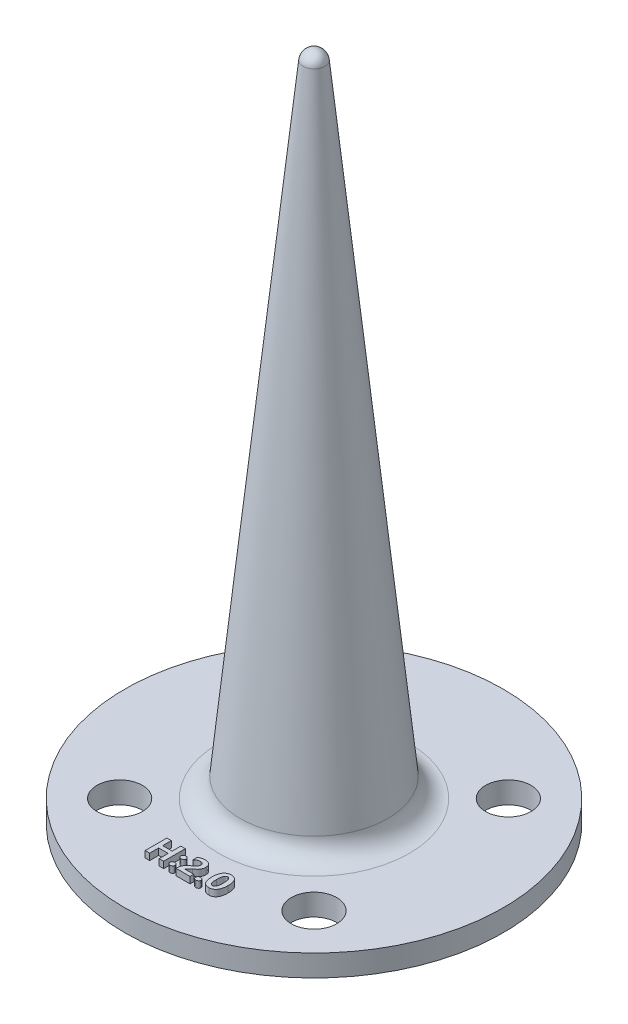
from build123d import *

# Parameters (mm, degrees)
SKETCH_1_R          = 17.5
EXTRUDE_1_DEPTH     = 2
SKETCH_2_R          = 2.1
CUT_EXTRUDE_1_DEPTH = 3
EXTRUDE_2_DEPTH     = 0.6


with BuildPart() as part:
    # 草图1 → 凸台-拉伸1 (new body)
    with BuildSketch(Plane(origin=(0, 0, 0), x_dir=(1, 0, 0), z_dir=(0, 1, 0))):
        Circle(SKETCH_1_R)
    extrude(amount=EXTRUDE_1_DEPTH)

    # 草图2 → 切除-拉伸1 (cut, through all)
    with BuildSketch(Plane(origin=(0, 2, 0), x_dir=(1, 0, 0), z_dir=(0, 1, 0))):
        with Locations((-8.980256121, 8.980256121)):
            Circle(SKETCH_2_R)
        with Locations((8.980256121, 8.980256121)):
            Circle(SKETCH_2_R)
        with Locations((8.980256121, -8.980256121)):
            Circle(SKETCH_2_R)
        with Locations((-8.980256121, -8.980256121)):
            Circle(SKETCH_2_R)
    extrude(amount=-CUT_EXTRUDE_1_DEPTH, mode=Mode.SUBTRACT)

    # 草图3 → 旋转1 (revolve)
    with BuildSketch(Plane.XY):
        with BuildLine():
            Line((0, 2), (0, 62))
            ThreePointArc((0, 62), (0.673890627, 61.740633618), (1, 61.096388188))
            Line((1, 61.096388188), (6.817452757, 3.797980459))
            ThreePointArc((6.817452757, 3.797980459), (7.466335687, 2.516079672), (8.807223624, 2))
            Line((8.807223624, 2), (8.5, 2))
            Line((8.5, 2), (8.5, 0))
            Line((8.5, 0), (3.5, 0))
            Line((3.5, 0), (3, 0))
            Line((3, 0), (3, -0.5))
            Line((3, -0.5), (3, -1.5))
            ThreePointArc((3, -1.5), (2.853553391, -1.853553391), (2.5, -2))
            Line((2.5, -2), (0, -2))
            Line((0, -2), (0, 2))
        make_face()
    revolve(axis=Axis((0, 2, 0), (0, 1, 0)))

    # 草图4 → 凸台-拉伸2 (add)
    with BuildSketch(Plane(origin=(0, 2, 0), x_dir=(1, 0, 0), z_dir=(0, 1, 0))):
        Polygon((-1.323843075, -12.567331469), (-1.738477221, -12.567331469), (-1.738477221, -11.738063176), (-2.616526001, -11.738063176), (-2.616526001, -12.567331469), (-3.031160148, -12.567331469), (-3.031160148, -10.567331469), (-2.616526001, -10.567331469), (-2.616526001, -11.372209517), (-1.738477221, -11.372209517), (-1.738477221, -10.567331469), (-1.323843075, -10.567331469), align=None)
        with BuildLine():
            add(Edge.make_bspline(
                [(-0.957989416, -11.346675981), (-0.95716336, -11.331445974), (-0.955544486, -11.301598759), (-0.941197888, -11.259229371), (-0.918119217, -11.221146155), (-0.88613114, -11.188748831), (-0.848424144, -11.161948655), (-0.806167375, -11.142050636), (-0.76018352, -11.130416952), (-0.728380096, -11.129019069), (-0.712181489, -11.128307078)],
                knots=[0, 0, 0, 0, 4.5581e-05, 8.9327e-05, 0.000132595, 0.000178144, 0.000224882, 0.000270744, 0.000317513, 0.000366062, 0.000366062, 0.000366062, 0.000366062], degree=3))
            add(Edge.make_bspline(
                [(-0.712181489, -11.128307078), (-0.695851189, -11.12899747), (-0.664034664, -11.13034257), (-0.618206773, -11.142087334), (-0.576404646, -11.161745304), (-0.539702879, -11.18892213), (-0.508433005, -11.22116108), (-0.486265945, -11.259379701), (-0.472227311, -11.301630702), (-0.470875143, -11.331447409), (-0.470184538, -11.346675981)],
                knots=[0, 0, 0, 0, 4.8929e-05, 9.5329e-05, 0.000140846, 0.000186657, 0.00023168, 0.000274556, 0.000318185, 0.000363729, 0.000363729, 0.000363729, 0.000363729], degree=3))
            add(Edge.make_bspline(
                [(-0.470184538, -11.346675981), (-0.470849899, -11.362415764), (-0.472142348, -11.392989926), (-0.486282231, -11.436206274), (-0.508206147, -11.475112275), (-0.539662097, -11.507587912), (-0.576920566, -11.534398068), (-0.619684238, -11.553615456), (-0.666968723, -11.565357894), (-0.700042897, -11.566659034), (-0.717135758, -11.567331469)],
                knots=[0, 0, 0, 0, 4.7062e-05, 9.1417e-05, 0.000134952, 0.000179975, 0.000225872, 0.00027192, 0.000319799, 0.000371008, 0.000371008, 0.000371008, 0.000371008], degree=3))
            add(Edge.make_bspline(
                [(-0.717135758, -11.567331469), (-0.733605837, -11.56670081), (-0.765483119, -11.565480191), (-0.81124129, -11.553045824), (-0.852871025, -11.533211309), (-0.889397668, -11.505530627), (-0.920092508, -11.472566482), (-0.941773297, -11.43396112), (-0.955978362, -11.391735934), (-0.957309534, -11.361909514), (-0.957989416, -11.346675981)],
                knots=[0, 0, 0, 0, 4.9309e-05, 9.5436e-05, 0.000141117, 0.000186849, 0.000232172, 0.000275187, 0.000318816, 0.00036436, 0.00036436, 0.00036436, 0.00036436], degree=3))
        make_face()
        with BuildLine():
            add(Edge.make_bspline(
                [(-0.957989416, -12.371447322), (-0.95718102, -12.356085454), (-0.955603155, -12.326101464), (-0.941098665, -12.283549923), (-0.918237461, -12.245222672), (-0.886233407, -12.212725737), (-0.848299387, -12.186393303), (-0.806183118, -12.166417675), (-0.760179376, -12.154813304), (-0.728378697, -12.153411375), (-0.712181489, -12.152697322)],
                knots=[0, 0, 0, 0, 4.596e-05, 8.9706e-05, 0.0001333, 0.000178849, 0.000225368, 0.000271229, 0.000317999, 0.000366548, 0.000366548, 0.000366548, 0.000366548], degree=3))
            add(Edge.make_bspline(
                [(-0.712181489, -12.152697322), (-0.69584372, -12.153353103), (-0.663980798, -12.154632047), (-0.618174177, -12.1668924), (-0.576381144, -12.186911133), (-0.539671288, -12.214464672), (-0.508527719, -12.24703996), (-0.48634338, -12.285186275), (-0.472257807, -12.327030226), (-0.470883531, -12.356472302), (-0.470184538, -12.371447322)],
                knots=[0, 0, 0, 0, 4.8929e-05, 9.5425e-05, 0.000141105, 0.000187143, 0.000232444, 0.00027532, 0.000318586, 0.000363371, 0.000363371, 0.000363371, 0.000363371], degree=3))
            add(Edge.make_bspline(
                [(-0.470184538, -12.371447322), (-0.470849811, -12.3871873), (-0.47214209, -12.41776184), (-0.486283189, -12.460975495), (-0.508202569, -12.499891532), (-0.539676089, -12.532328299), (-0.576824735, -12.55925669), (-0.619788185, -12.577900881), (-0.666954143, -12.589780455), (-0.70003793, -12.591060289), (-0.717135758, -12.591721712)],
                knots=[0, 0, 0, 0, 4.7062e-05, 9.1417e-05, 0.000134952, 0.000179975, 0.000225872, 0.000271763, 0.000319642, 0.000370851, 0.000370851, 0.000370851, 0.000370851], degree=3))
            add(Edge.make_bspline(
                [(-0.717135758, -12.591721712), (-0.733224602, -12.591077211), (-0.764597137, -12.589820463), (-0.80965975, -12.577387318), (-0.851220081, -12.557735722), (-0.888258352, -12.530469062), (-0.919151982, -12.49720983), (-0.942051611, -12.459037965), (-0.955335427, -12.41638076), (-0.957091175, -12.386655017), (-0.957989416, -12.371447322)],
                knots=[0, 0, 0, 0, 4.8169e-05, 9.3928e-05, 0.0001391, 0.000185444, 0.000231025, 0.000274423, 0.000317937, 0.000363517, 0.000363517, 0.000363517, 0.000363517], degree=3))
        make_face()
        with BuildLine():
            Line((0.302300218, -12.225868054), (1.115181316, -12.225868054))
            Line((1.115181316, -12.225868054), (1.115181316, -12.567331469))
            Line((1.115181316, -12.567331469), (-0.177501611, -12.567331469))
            Line((-0.177501611, -12.567331469), (-0.177501611, -12.419465615))
            add(Edge.make_bspline(
                [(-0.177501611, -12.419465615), (-0.17695135, -12.394012033), (-0.175872822, -12.344122234), (-0.164168835, -12.27113647), (-0.146579914, -12.20139775), (-0.121029132, -12.134990743), (-0.088953921, -12.071796884), (-0.052440887, -12.010355596), (-0.009719241, -11.95164494), (0.030043961, -11.904088875), (0.065689748, -11.866292956), (0.096513551, -11.836998947), (0.130314519, -11.806104684), (0.167751704, -11.774166102), (0.208572584, -11.740877334), (0.253158178, -11.706883939), (0.300845552, -11.671148845), (0.33424847, -11.647654921), (0.351461803, -11.635547932)],
                knots=[0, 0, 0, 0, 7.6297e-05, 0.000149544, 0.000221179, 0.000291744, 0.000362473, 0.000433582, 0.000505928, 0.000580047, 0.000619405, 0.000661721, 0.000707583, 0.000756772, 0.000809328, 0.000865582, 0.000924957, 0.000988087, 0.000988087, 0.000988087, 0.000988087], degree=3))
            add(Edge.make_bspline(
                [(0.351461803, -11.635547932), (0.367039597, -11.623963625), (0.39734499, -11.601427252), (0.440090709, -11.566964562), (0.480196071, -11.534481677), (0.515635387, -11.501988036), (0.54804717, -11.471226459), (0.576189786, -11.440999242), (0.601057762, -11.412066044), (0.62932072, -11.375597304), (0.657686293, -11.329104045), (0.682441537, -11.271158414), (0.697638273, -11.211141714), (0.699575647, -11.170440049), (0.700547169, -11.150029639)],
                knots=[0, 0, 0, 0, 5.8232e-05, 0.000113286, 0.000164715, 0.000213013, 0.000257484, 0.000298736, 0.000336847, 0.00037191, 0.000437074, 0.000499575, 0.000560394, 0.000621571, 0.000621571, 0.000621571, 0.000621571], degree=3))
            add(Edge.make_bspline(
                [(0.700547169, -11.150029639), (0.70034174, -11.139348855), (0.699941985, -11.118564513), (0.696440825, -11.088352586), (0.690864686, -11.060126142), (0.682789067, -11.033957923), (0.672602834, -11.009848657), (0.659929422, -10.988050016), (0.645179625, -10.968156612), (0.628090735, -10.950284972), (0.608488082, -10.934524777), (0.586477841, -10.921199027), (0.562506026, -10.909745713), (0.536154912, -10.900564467), (0.507567265, -10.893448971), (0.476757403, -10.888089926), (0.443618951, -10.885103855), (0.420827402, -10.884643423), (0.409007535, -10.884404639)],
                knots=[0, 0, 0, 0, 3.2033e-05, 6.2334e-05, 9.1109e-05, 0.000118231, 0.000144352, 0.000169453, 0.000193691, 0.000218488, 0.000243426, 0.000268917, 0.000295509, 0.000322991, 0.000352476, 0.000383802, 0.000416718, 0.000452179, 0.000452179, 0.000452179, 0.000452179], degree=3))
            add(Edge.make_bspline(
                [(0.409007535, -10.884404639), (0.387751303, -10.884920316), (0.34525862, -10.885951188), (0.282119243, -10.896525092), (0.219557516, -10.912481759), (0.157749125, -10.935035608), (0.096769454, -10.96438342), (0.036677531, -10.999917596), (-0.023002881, -11.041655558), (-0.060635022, -11.073738498), (-0.079940636, -11.090197322)],
                knots=[0, 0, 0, 0, 6.3716e-05, 0.000127373, 0.000191521, 0.000257226, 0.000324387, 0.000394257, 0.00046647, 0.000542542, 0.000542542, 0.000542542, 0.000542542], degree=3))
            Line((-0.079940636, -11.090197322), (-0.079940636, -10.71557842))
            add(Edge.make_bspline(
                [(-0.079940636, -10.71557842), (-0.058675113, -10.701774347), (-0.016428373, -10.674350753), (0.050219626, -10.639400852), (0.118594547, -10.609556019), (0.188858318, -10.584953652), (0.261229687, -10.566502652), (0.335391836, -10.552524654), (0.411623688, -10.544492216), (0.463105327, -10.543460785), (0.489038023, -10.542941225)],
                knots=[0, 0, 0, 0, 7.6026e-05, 0.000151035, 0.000225447, 0.00029969, 0.000374098, 0.000449293, 0.000525932, 0.000603722, 0.000603722, 0.000603722, 0.000603722], degree=3))
            add(Edge.make_bspline(
                [(0.489038023, -10.542941225), (0.512560682, -10.543317501), (0.558453503, -10.544051619), (0.625319805, -10.551582694), (0.688507189, -10.56308906), (0.747766624, -10.580004885), (0.803449276, -10.601190904), (0.855107992, -10.627834459), (0.903494167, -10.658485001), (0.947130596, -10.694667048), (0.987095939, -10.733941391), (1.021191598, -10.777976033), (1.050198682, -10.825445888), (1.074459103, -10.876287804), (1.092770001, -10.930967855), (1.105458259, -10.989122936), (1.113791928, -11.050832054), (1.114710129, -11.093217865), (1.115181316, -11.114968664)],
                knots=[0, 0, 0, 0, 7.054e-05, 0.000137624, 0.000201605, 0.000263009, 0.000322246, 0.000380025, 0.00043711, 0.000493714, 0.000549765, 0.000604882, 0.000660308, 0.000716393, 0.000773517, 0.000832875, 0.000894751, 0.000959974, 0.000959974, 0.000959974, 0.000959974], degree=3))
            add(Edge.make_bspline(
                [(1.115181316, -11.114968664), (1.114639664, -11.139265359), (1.113580681, -11.18676785), (1.104011334, -11.256120684), (1.089523556, -11.322142365), (1.067852781, -11.384591499), (1.040441697, -11.444120388), (1.007792065, -11.501522054), (0.970030467, -11.557374408), (0.933628125, -11.602195705), (0.900879082, -11.638063948), (0.872456133, -11.666211926), (0.840931075, -11.695953467), (0.80567076, -11.726751696), (0.767287418, -11.759164957), (0.725155052, -11.792747578), (0.679626012, -11.827629946), (0.647866934, -11.851046201), (0.631568511, -11.863063176)],
                knots=[0, 0, 0, 0, 7.2853e-05, 0.000142436, 0.000209649, 0.000275331, 0.000340304, 0.000406008, 0.000473234, 0.000542335, 0.000579019, 0.000618902, 0.000662308, 0.000709022, 0.00075933, 0.000813015, 0.00087064, 0.000931387, 0.000931387, 0.000931387, 0.000931387], degree=3))
            add(Edge.make_bspline(
                [(0.631568511, -11.863063176), (0.615912954, -11.874836855), (0.585858831, -11.897438901), (0.543004671, -11.930676787), (0.504283904, -11.961838331), (0.469254371, -11.990814628), (0.438735897, -12.018148974), (0.411758955, -12.04300171), (0.388783958, -12.06569163), (0.364692866, -12.092822217), (0.340695838, -12.123952009), (0.318986867, -12.159710362), (0.305269496, -12.193403371), (0.303238719, -12.215606922), (0.302300218, -12.225868054)],
                knots=[0, 0, 0, 0, 5.8766e-05, 0.000112813, 0.000162689, 0.000207873, 0.000249174, 0.000285578, 0.000317915, 0.000345987, 0.000394388, 0.000435565, 0.000471382, 0.000502156, 0.000502156, 0.000502156, 0.000502156], degree=3))
        make_face()
        with BuildLine():
            add(Edge.make_bspline(
                [(1.432254486, -12.371447322), (1.433062883, -12.356085454), (1.434640747, -12.326101464), (1.449145237, -12.283549923), (1.472006441, -12.245222672), (1.504010496, -12.212725737), (1.541944516, -12.186393303), (1.584060784, -12.166417675), (1.630064527, -12.154813304), (1.661865205, -12.153411375), (1.678062413, -12.152697322)],
                knots=[0, 0, 0, 0, 4.596e-05, 8.9706e-05, 0.0001333, 0.000178849, 0.000225368, 0.000271229, 0.000317999, 0.000366548, 0.000366548, 0.000366548, 0.000366548], degree=3))
            add(Edge.make_bspline(
                [(1.678062413, -12.152697322), (1.694400183, -12.153353103), (1.726263105, -12.154632047), (1.772069725, -12.1668924), (1.813862758, -12.186911133), (1.850572614, -12.214464672), (1.881716184, -12.24703996), (1.903900523, -12.285186275), (1.917986095, -12.327030226), (1.919360371, -12.356472302), (1.920059364, -12.371447322)],
                knots=[0, 0, 0, 0, 4.8929e-05, 9.5425e-05, 0.000141105, 0.000187143, 0.000232444, 0.00027532, 0.000318586, 0.000363371, 0.000363371, 0.000363371, 0.000363371], degree=3))
            add(Edge.make_bspline(
                [(1.920059364, -12.371447322), (1.919394091, -12.3871873), (1.918101813, -12.41776184), (1.903960713, -12.460975495), (1.882041333, -12.499891532), (1.850567813, -12.532328299), (1.813419168, -12.55925669), (1.770455718, -12.577900881), (1.72328976, -12.589780455), (1.690205973, -12.591060289), (1.673108145, -12.591721712)],
                knots=[0, 0, 0, 0, 4.7062e-05, 9.1417e-05, 0.000134952, 0.000179975, 0.000225872, 0.000271763, 0.000319642, 0.000370851, 0.000370851, 0.000370851, 0.000370851], degree=3))
            add(Edge.make_bspline(
                [(1.673108145, -12.591721712), (1.657019301, -12.591077211), (1.625646765, -12.589820463), (1.580584152, -12.577387318), (1.539023821, -12.557735722), (1.50198555, -12.530469062), (1.47109192, -12.49720983), (1.448192291, -12.459037965), (1.434908475, -12.41638076), (1.433152727, -12.386655017), (1.432254486, -12.371447322)],
                knots=[0, 0, 0, 0, 4.8169e-05, 9.3928e-05, 0.0001391, 0.000185444, 0.000231025, 0.000274423, 0.000317937, 0.000363517, 0.000363517, 0.000363517, 0.000363517], degree=3))
        make_face()
        with BuildLine():
            add(Edge.make_bspline(
                [(2.163961803, -11.599343664), (2.164564428, -11.557790574), (2.165736072, -11.47700156), (2.174269597, -11.359623021), (2.189591363, -11.249814531), (2.210291711, -11.147643327), (2.236766009, -11.052786324), (2.269874155, -10.965814616), (2.308840212, -10.88619311), (2.353755047, -10.814263336), (2.404564667, -10.750256357), (2.460788125, -10.694440754), (2.522761513, -10.647535845), (2.590008535, -10.609113232), (2.662659213, -10.57926711), (2.740568731, -10.557924555), (2.823858042, -10.545206624), (2.881142169, -10.543709386), (2.910531925, -10.542941225)],
                knots=[0, 0, 0, 0, 0.000124656, 0.000242361, 0.000352793, 0.000457056, 0.000554894, 0.000647895, 0.00073584, 0.00082043, 0.00090179, 0.000980479, 0.001057462, 0.001134275, 0.001212195, 0.001292447, 0.001376096, 0.001464229, 0.001464229, 0.001464229, 0.001464229], degree=3))
            add(Edge.make_bspline(
                [(2.910531925, -10.542941225), (2.93852253, -10.543603125), (2.992990287, -10.544891136), (3.071895914, -10.556878365), (3.145489596, -10.576680766), (3.213639305, -10.604542959), (3.276537768, -10.640257988), (3.333648174, -10.684175625), (3.38570391, -10.735750408), (3.431774241, -10.795622542), (3.472375647, -10.863351353), (3.507126605, -10.938913966), (3.53756529, -11.021857284), (3.560991264, -11.11313424), (3.580080779, -11.212005478), (3.593582161, -11.318798905), (3.601562154, -11.433442852), (3.602501273, -11.512440072), (3.602986194, -11.553230859)],
                knots=[0, 0, 0, 0, 8.3928e-05, 0.000163318, 0.000238757, 0.000312076, 0.000383594, 0.000455091, 0.000527581, 0.00060282, 0.000681118, 0.000763978, 0.000851986, 0.000945811, 0.001046338, 0.001153923, 0.001268532, 0.001390894, 0.001390894, 0.001390894, 0.001390894], degree=3))
            add(Edge.make_bspline(
                [(3.602986194, -11.553230859), (3.602412661, -11.593517629), (3.601298541, -11.671777047), (3.592362315, -11.785647432), (3.578255989, -11.89250351), (3.557752222, -11.992396127), (3.531176465, -12.085179992), (3.498863148, -12.170939615), (3.460700711, -12.249679572), (3.41661925, -12.321030059), (3.366894951, -12.384808628), (3.31191854, -12.440402016), (3.251542833, -12.487679492), (3.185309296, -12.52535312), (3.11436143, -12.555362827), (3.038096284, -12.576789786), (2.95656095, -12.589431253), (2.900414678, -12.590945968), (2.871659974, -12.591721712)],
                knots=[0, 0, 0, 0, 0.000120846, 0.000234751, 0.000342437, 0.00044401, 0.000540382, 0.000631688, 0.000718612, 0.000802475, 0.000882828, 0.000960707, 0.001036481, 0.001112112, 0.001188625, 0.001267042, 0.001349185, 0.001435415, 0.001435415, 0.001435415, 0.001435415], degree=3))
            add(Edge.make_bspline(
                [(2.871659974, -12.591721712), (2.843031787, -12.591077096), (2.787421034, -12.589824917), (2.706826583, -12.577631073), (2.631700484, -12.558460658), (2.562058224, -12.531206013), (2.497767654, -12.496335083), (2.439103669, -12.453473241), (2.386380025, -12.402298546), (2.338976762, -12.343745654), (2.297335049, -12.277264469), (2.261528791, -12.203046256), (2.231100402, -12.121255088), (2.206627308, -12.031658835), (2.187139289, -11.934518247), (2.173888157, -11.829568513), (2.165247593, -11.716994071), (2.164399314, -11.639376103), (2.163961803, -11.599343664)],
                knots=[0, 0, 0, 0, 8.5832e-05, 0.000166729, 0.000243912, 0.000318008, 0.000390486, 0.000462747, 0.000535249, 0.000610302, 0.000688227, 0.000770039, 0.000857106, 0.000949659, 0.00104839, 0.001154086, 0.001266822, 0.001386897, 0.001386897, 0.001386897, 0.001386897], degree=3))
        make_face()
        with BuildLine():
            add(Edge.make_bspline(
                [(2.57859595, -11.58905403), (2.578751886, -11.616753184), (2.579053907, -11.670401316), (2.583163143, -11.748038178), (2.58855616, -11.820409393), (2.596803882, -11.887463698), (2.607924227, -11.949098985), (2.620695165, -12.005567388), (2.636006363, -12.056669525), (2.654617098, -12.102210986), (2.674339079, -12.142967068), (2.697416385, -12.177948343), (2.722764946, -12.2077962), (2.750571619, -12.23247953), (2.781165857, -12.251453322), (2.813993536, -12.264917061), (2.849272375, -12.273237202), (2.873645959, -12.274170211), (2.886141681, -12.274648542)],
                knots=[0, 0, 0, 0, 8.3087e-05, 0.000160924, 0.000233178, 0.000300773, 0.000363493, 0.000420993, 0.000474397, 0.000523298, 0.000568462, 0.000610002, 0.000648651, 0.000685649, 0.000721077, 0.000756109, 0.0007917, 0.000829143, 0.000829143, 0.000829143, 0.000829143], degree=3))
            add(Edge.make_bspline(
                [(2.886141681, -12.274648542), (2.898388997, -12.274193007), (2.922424935, -12.273299), (2.957080338, -12.264565602), (2.989441464, -12.250618226), (3.019300194, -12.230970902), (3.046735258, -12.205685209), (3.071463222, -12.174825551), (3.093920092, -12.138681491), (3.114205814, -12.097235792), (3.131545847, -12.050028052), (3.146475165, -11.99733178), (3.160100441, -11.939439242), (3.169874533, -11.875803248), (3.17837029, -11.806810974), (3.184384239, -11.732183337), (3.187723288, -11.652093681), (3.188138058, -11.596933255), (3.188352047, -11.568474761)],
                knots=[0, 0, 0, 0, 3.6682e-05, 7.1991e-05, 0.000106469, 0.000141985, 0.00017867, 0.000217952, 0.000260247, 0.000306095, 0.000356141, 0.000410897, 0.000470339, 0.000534433, 0.000603919, 0.000678863, 0.000758967, 0.00084434, 0.00084434, 0.00084434, 0.00084434], degree=3))
            add(Edge.make_bspline(
                [(3.188352047, -11.568474761), (3.188146901, -11.53988873), (3.187749214, -11.484473363), (3.184294758, -11.404146533), (3.178721894, -11.329390641), (3.170732148, -11.260227419), (3.160728338, -11.196424434), (3.147673953, -11.138223183), (3.13309668, -11.085395179), (3.115922784, -11.038227027), (3.096639345, -10.996319738), (3.07471881, -10.960050861), (3.050309401, -10.929386818), (3.024047605, -10.903694589), (2.994782804, -10.884084765), (2.963204732, -10.870094479), (2.929417322, -10.861396573), (2.906010608, -10.860479367), (2.89414473, -10.860014395)],
                knots=[0, 0, 0, 0, 8.5755e-05, 0.000166239, 0.000241153, 0.000310594, 0.000375064, 0.000434794, 0.000489445, 0.000539359, 0.000585221, 0.000627639, 0.000666147, 0.000702535, 0.000737416, 0.000771196, 0.000805765, 0.000841307, 0.000841307, 0.000841307, 0.000841307], degree=3))
            add(Edge.make_bspline(
                [(2.89414473, -10.860014395), (2.881382268, -10.860432965), (2.856299346, -10.861255607), (2.820195488, -10.870544149), (2.786241083, -10.884620246), (2.75527104, -10.905368193), (2.726335113, -10.931102203), (2.700333537, -10.962834764), (2.677130016, -11.000256895), (2.656253007, -11.043219791), (2.63761987, -11.091781983), (2.62174436, -11.146103184), (2.608610929, -11.206121332), (2.597673779, -11.271762247), (2.58888011, -11.343082239), (2.583092091, -11.420024769), (2.579069708, -11.502629107), (2.578757534, -11.559577125), (2.57859595, -11.58905403)],
                knots=[0, 0, 0, 0, 3.8203e-05, 7.5083e-05, 0.000111112, 0.000148002, 0.000186328, 0.000226926, 0.000270594, 0.000318146, 0.000370023, 0.000426456, 0.000487757, 0.000554231, 0.000626033, 0.000703256, 0.000785661, 0.000874083, 0.000874083, 0.000874083, 0.000874083], degree=3))
        make_face(mode=Mode.SUBTRACT)
    extrude(amount=EXTRUDE_2_DEPTH)


solid = part.part
